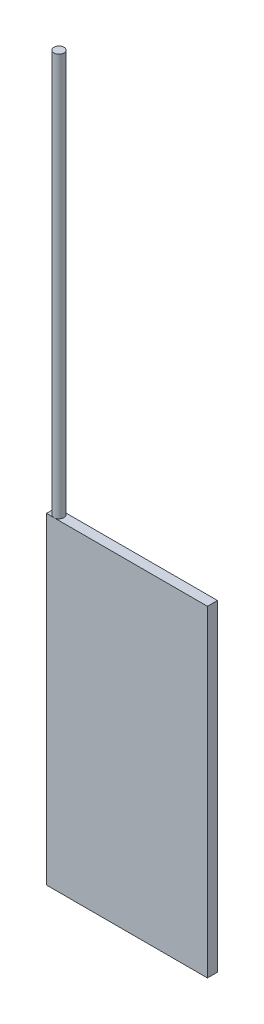
from build123d import *

# Parameters (mm, degrees)
SKETCH1_W           = 50.8
SKETCH1_H           = 101.6
BOSS_EXTRUDE1_DEPTH = 3.175
SKETCH2_R           = 1.5875
BOSS_EXTRUDE2_DEPTH = 127


with BuildPart() as part:
    # Sketch1 → Boss-Extrude1 (new body)
    with BuildSketch(Plane.XY):
        with Locations((25.4, 50.8)):
            Rectangle(SKETCH1_W, SKETCH1_H)
    extrude(amount=BOSS_EXTRUDE1_DEPTH)

    # Sketch2 → Boss-Extrude2 (add)
    with BuildSketch(Plane(origin=(0, 101.6, 0), x_dir=(1, 0, 0), z_dir=(0, 1, 0))):
        with Locations((2.33921931, -1.5875)):
            Circle(SKETCH2_R)
    extrude(amount=BOSS_EXTRUDE2_DEPTH)


solid = part.part
